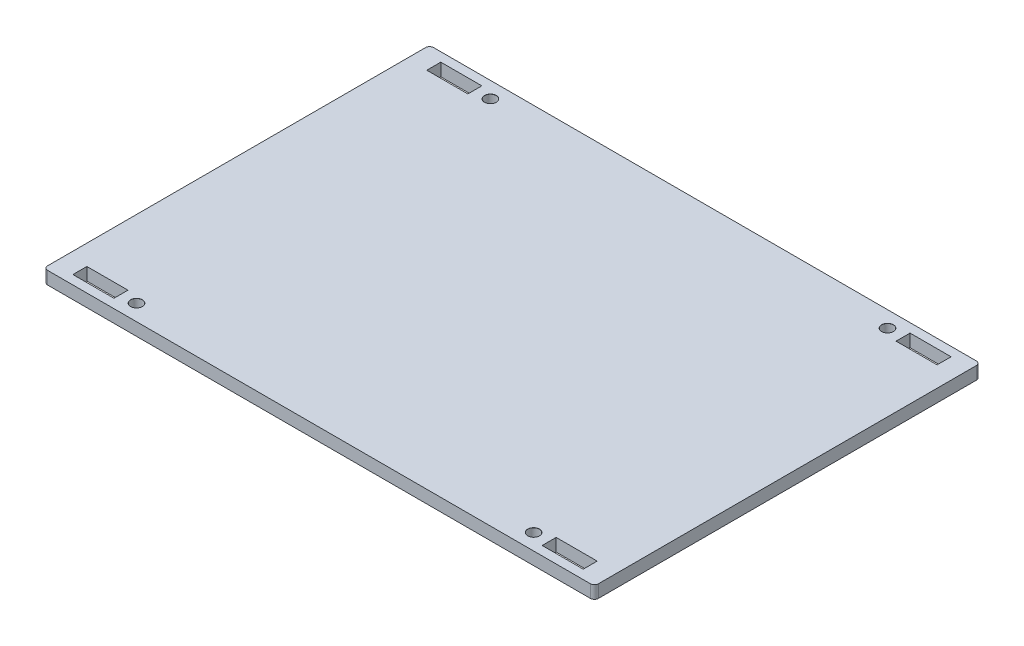
from build123d import *

# Parameters (mm, degrees)
SKETCH1_W                                      = 137.49
SKETCH1_H                                      = 96.345
BOSS_EXTRUDE1_DEPTH                            = 3.175
SKETCH1_3_W                                    = 10.25
SKETCH1_3_H                                    = 3.4925
CUT_EXTRUDE1_DEPTH                             = 85.003246403
M2_5_CLEARANCE_HOLE1_D                         = 2.9
M2_5_CLEARANCE_HOLE1_CSINK_D                   = 2.95
M2_5_CLEARANCE_HOLE1_CSINK_ANGLE               = 100
MIRROR1_AT_THE_SECOND_PLANE_COPY_1_SKETC_W     = 10.25
MIRROR1_AT_THE_SECOND_PLANE_COPY_1_SKETC_H     = 3.4925
MIRROR1_AT_THE_SECOND_PLANE_COPY_1_DEPTH       = 85.003246403
MIRROR1_AT_THE_SECOND_PLANE_COPY_2_D           = 2.9
MIRROR1_AT_THE_SECOND_PLANE_COPY_2_CSINK_D     = 2.95
MIRROR1_AT_THE_SECOND_PLANE_COPY_2_CSINK_ANGLE = 100
FILLET1_R                                      = 1


with BuildPart() as part:
    # Sketch1 → Boss-Extrude1 (new body)
    with BuildSketch(Plane(origin=(0, 0, 0), x_dir=(1, 0, 0), z_dir=(0, 1, 0))):
        Rectangle(SKETCH1_W, SKETCH1_H)
    extrude(amount=BOSS_EXTRUDE1_DEPTH)

    # Sketch1_3 → Cut-Extrude1 (cut, symmetric)
    with BuildSketch(Plane(origin=(0, 0, 0), x_dir=(1, 0, 0), z_dir=(0, 1, 0))):
        with Locations((-58.57, 44.1725)):
            Rectangle(SKETCH1_3_W, SKETCH1_3_H)
    cut_extrude1 = extrude(amount=CUT_EXTRUDE1_DEPTH, both=True, mode=Mode.SUBTRACT)

    # M2.5 Clearance Hole1 (through all)
    with Locations(Plane(origin=(0, 3.175, 0), x_dir=(1, 0, 0), z_dir=(0, 1, 0))):
        with Locations((-49.57, 44.1725)):
            m2_5_clearance_hole1 = CounterSinkHole(M2_5_CLEARANCE_HOLE1_D / 2, M2_5_CLEARANCE_HOLE1_CSINK_D / 2, counter_sink_angle=M2_5_CLEARANCE_HOLE1_CSINK_ANGLE)

    # Mirror1: Cut-Extrude1, M2.5 Clearance Hole1 across plane
    add(cut_extrude1.mirror(Plane(origin=(0, 0, 0), x_dir=(0, 0, 1), z_dir=(1, 0, 0))), mode=Mode.SUBTRACT)
    add(m2_5_clearance_hole1.mirror(Plane(origin=(0, 0, 0), x_dir=(0, 0, 1), z_dir=(1, 0, 0))), mode=Mode.SUBTRACT)

    # Mirror1 at the second plane: Cut-Extrude1, M2.5 Clearance Hole1 across plane
    add(cut_extrude1.mirror(Plane.XY), mode=Mode.SUBTRACT)
    add(m2_5_clearance_hole1.mirror(Plane.XY), mode=Mode.SUBTRACT)

    # Mirror1 at the second plane copy 1 sketc → Mirror1 at the second plane copy 1 (cut, symmetric)
    with BuildSketch(Plane(origin=(0, 0, 0), x_dir=(-1, 0, 0), z_dir=(0, 1, 0))):
        with Locations((-58.57, 44.1725)):
            Rectangle(MIRROR1_AT_THE_SECOND_PLANE_COPY_1_SKETC_W, MIRROR1_AT_THE_SECOND_PLANE_COPY_1_SKETC_H)
    extrude(amount=MIRROR1_AT_THE_SECOND_PLANE_COPY_1_DEPTH, both=True, mode=Mode.SUBTRACT)

    # Mirror1 at the second plane copy 2 (through all)
    with Locations(Plane(origin=(0, 3.175, 0), x_dir=(-1, 0, 0), z_dir=(0, 1, 0))):
        with Locations((-49.57, 44.1725)):
            CounterSinkHole(MIRROR1_AT_THE_SECOND_PLANE_COPY_2_D / 2, MIRROR1_AT_THE_SECOND_PLANE_COPY_2_CSINK_D / 2, counter_sink_angle=MIRROR1_AT_THE_SECOND_PLANE_COPY_2_CSINK_ANGLE)

    # Fillet1
    fillet1_edges = [part.edges().sort_by_distance(p)[0] for p in [
        (68.745, 1.5875, -48.1725),
        (68.745, 1.5875, 48.1725),
        (-68.745, 1.5875, 48.1725),
        (-68.745, 1.5875, -48.1725),
    ]]
    fillet(fillet1_edges, radius=FILLET1_R)


solid = part.part
